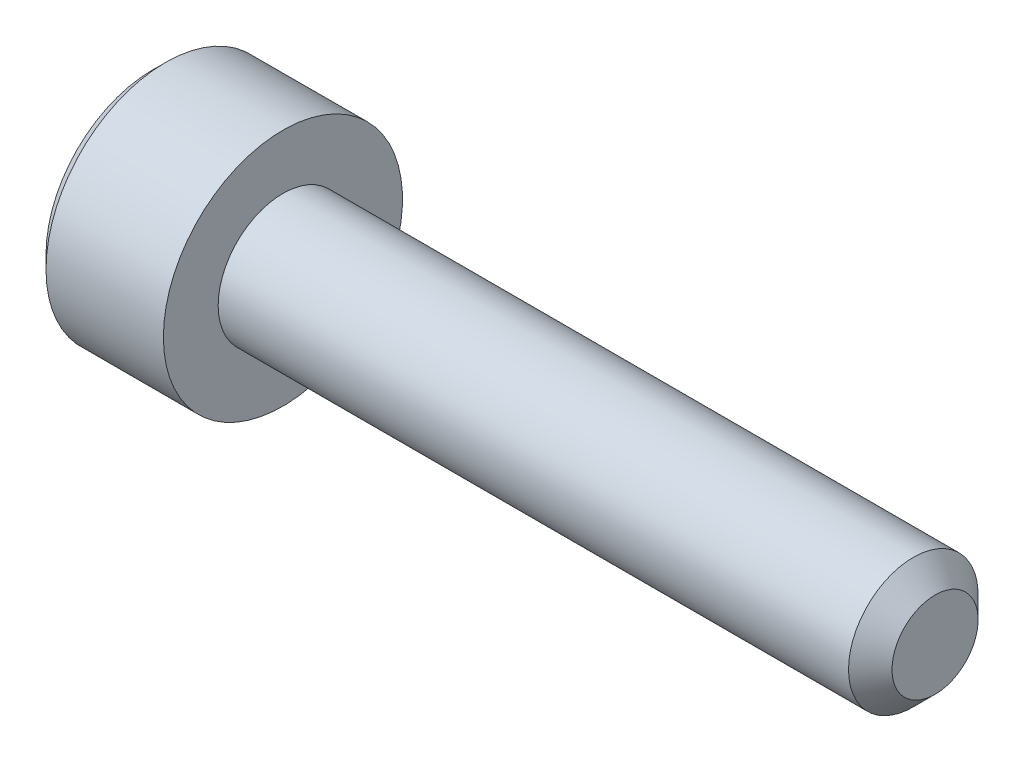
from build123d import *

# Parameters (mm, degrees)
CHAMFER1_SIZE      = 0.5
CHAMFER2_SIZE      = 0.3
CUT_EXTRUDE1_DEPTH = 2.5
CHAMFER3_SIZE      = 0.3


with BuildPart() as part:
    # Sketch1 → Revolve1 (revolve)
    with BuildSketch(Plane.XY):
        Polygon((0, 0), (0, 2.75), (3, 2.75), (3, 1.49), (18, 1.49), (18, 0), align=None)
    revolve(axis=Axis((-88.705490849, 0, 0), (1, 0, 0)))

    # Chamfer1
    chamfer1_edges = [part.edges().sort_by_distance(p)[0] for p in [
        (18, -1.49, 0),
    ]]
    chamfer(chamfer1_edges, length=CHAMFER1_SIZE)

    # Chamfer2
    chamfer2_edges = [part.edges().sort_by_distance(p)[0] for p in [
        (0, -2.75, 0),
    ]]
    chamfer(chamfer2_edges, length=CHAMFER2_SIZE)

    # Sketch3 → Cut-Extrude1 (cut)
    with BuildSketch(Plane(origin=(0, 0, 0), x_dir=(0, 0, -1), z_dir=(1, 0, 0))):
        Polygon((-1.443375673, 0), (-0.721687836, -1.25), (0.721687836, -1.25), (1.443375673, 0), (0.721687836, 1.25), (-0.721687836, 1.25), align=None)
    extrude(amount=CUT_EXTRUDE1_DEPTH, mode=Mode.SUBTRACT)

    # Chamfer3
    chamfer3_edges = [part.edges().sort_by_distance(p)[0] for p in [
        (0, 1.25, 0),
        (0, 0.625, 1.082531755),
        (0, -0.625, 1.082531755),
        (0, -1.25, 0),
        (0, -0.625, -1.082531755),
        (0, 0.625, -1.082531755),
    ]]
    chamfer(chamfer3_edges, length=CHAMFER3_SIZE)


solid = part.part
